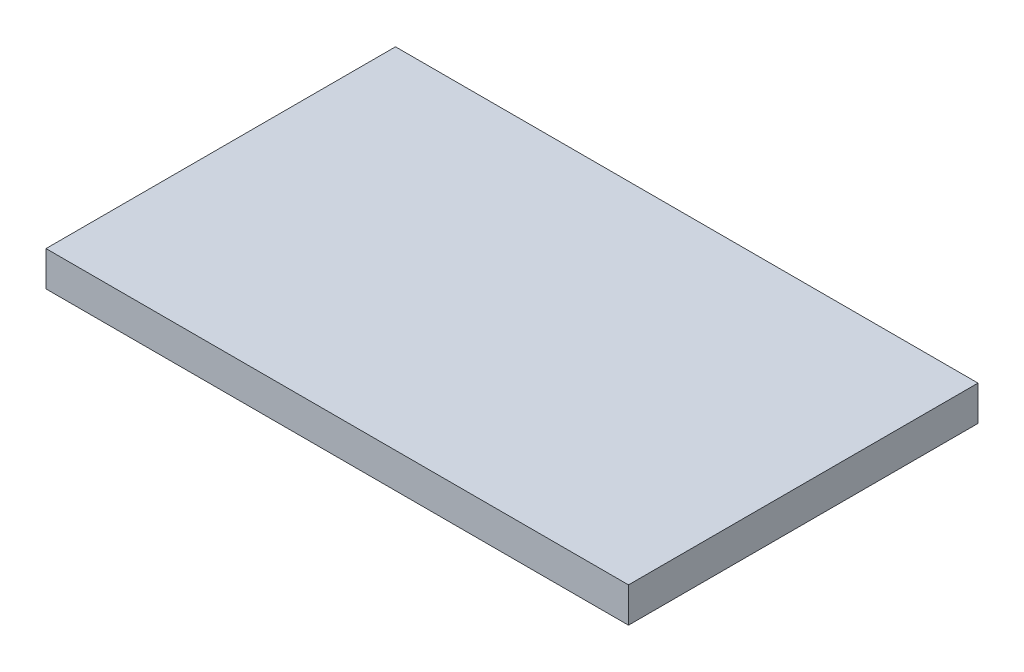
from build123d import *

# Parameters (mm, degrees)
SKETCH1_W           = 10
SKETCH1_H           = 6
BOSS_EXTRUDE1_DEPTH = 0.6


with BuildPart() as part:
    # Sketch1 → Boss-Extrude1 (new body)
    with BuildSketch(Plane(origin=(0, 0, 0), x_dir=(1, 0, 0), z_dir=(0, 1, 0))):
        with Locations((5, 3)):
            Rectangle(SKETCH1_W, SKETCH1_H)
    extrude(amount=BOSS_EXTRUDE1_DEPTH)


solid = part.part
